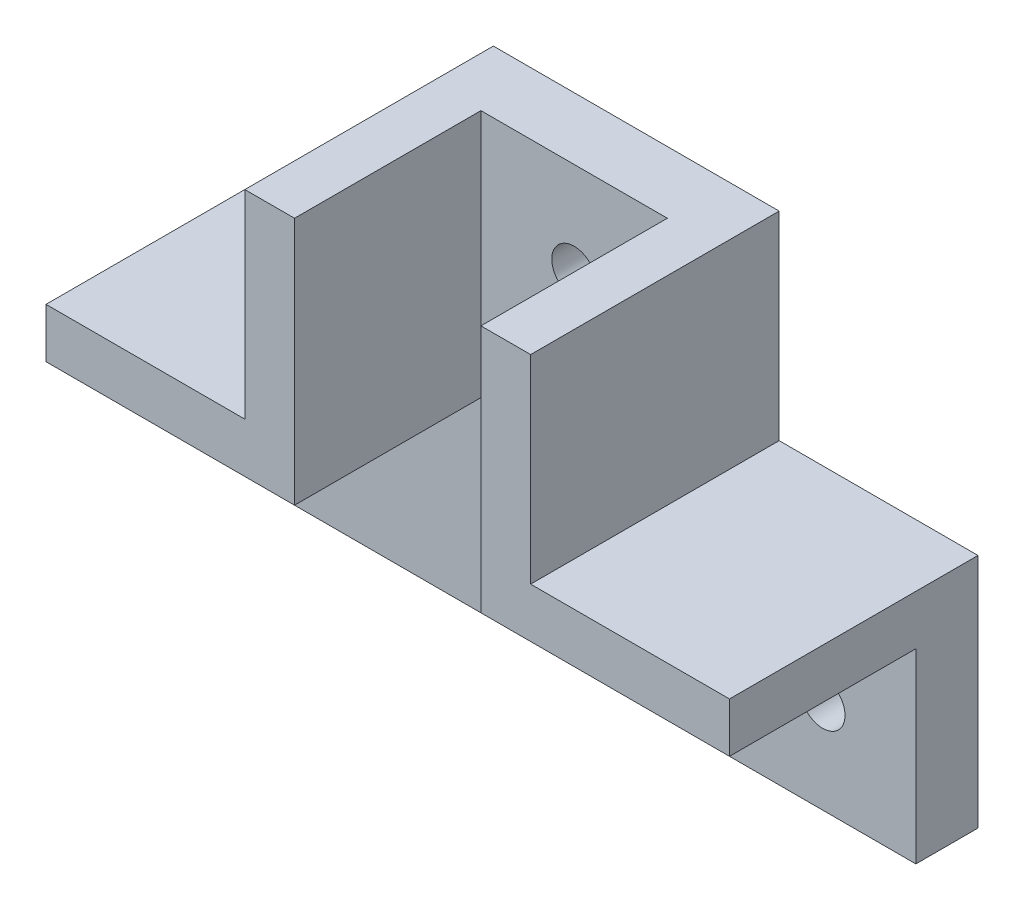
from build123d import *

# Parameters (mm, degrees)
BOSS_EXTRUDE1_DEPTH = 5
BOSS_EXTRUDE2_DEPTH = 20
SKETCH6_R           = 1.8
CUT_EXTRUDE3_DEPTH  = 6


with BuildPart() as part:
    # Sketch1 → Boss-Extrude1 (new body)
    with BuildSketch(Plane.XY):
        Polygon((14.31372549, -4.264705882), (34.31372549, -4.264705882), (34.31372549, -19.264705882), (-20.68627451, -19.264705882), (-20.68627451, -4.264705882), (-0.68627451, -4.264705882), (-0.68627451, 15.735294118), (14.31372549, 15.735294118), align=None)
    extrude(amount=BOSS_EXTRUDE1_DEPTH)

    # Sketch2 → Boss-Extrude2 (add)
    with BuildSketch(Plane(origin=(0, 0, 0), x_dir=(-1, 0, 0), z_dir=(0, 0, -1))):
        Polygon((0.68627451, 15.735294118), (4.68627451, 15.735294118), (4.68627451, -0.264705882), (6.079970528, -0.264705882), (20.68627451, -0.264705882), (20.68627451, -4.264705882), (0.68627451, -4.264705882), align=None)
    boss_extrude2 = extrude(amount=-BOSS_EXTRUDE2_DEPTH)

    # Mirror1: Boss-Extrude2 across plane
    add(boss_extrude2.mirror(Plane.ZY.offset(-6.81372549)))

    # Sketch6 → Cut-Extrude3 (cut, through all)
    with BuildSketch(Plane.XY.offset(5)):
        with Locations((6.81372549, 8.235294118)):
            Circle(SKETCH6_R)
        with Locations((-13.18627451, -11.764705882)):
            Circle(SKETCH6_R)
        with Locations((26.81372549, -11.764705882)):
            Circle(SKETCH6_R)
    extrude(amount=-CUT_EXTRUDE3_DEPTH, mode=Mode.SUBTRACT)


solid = part.part
